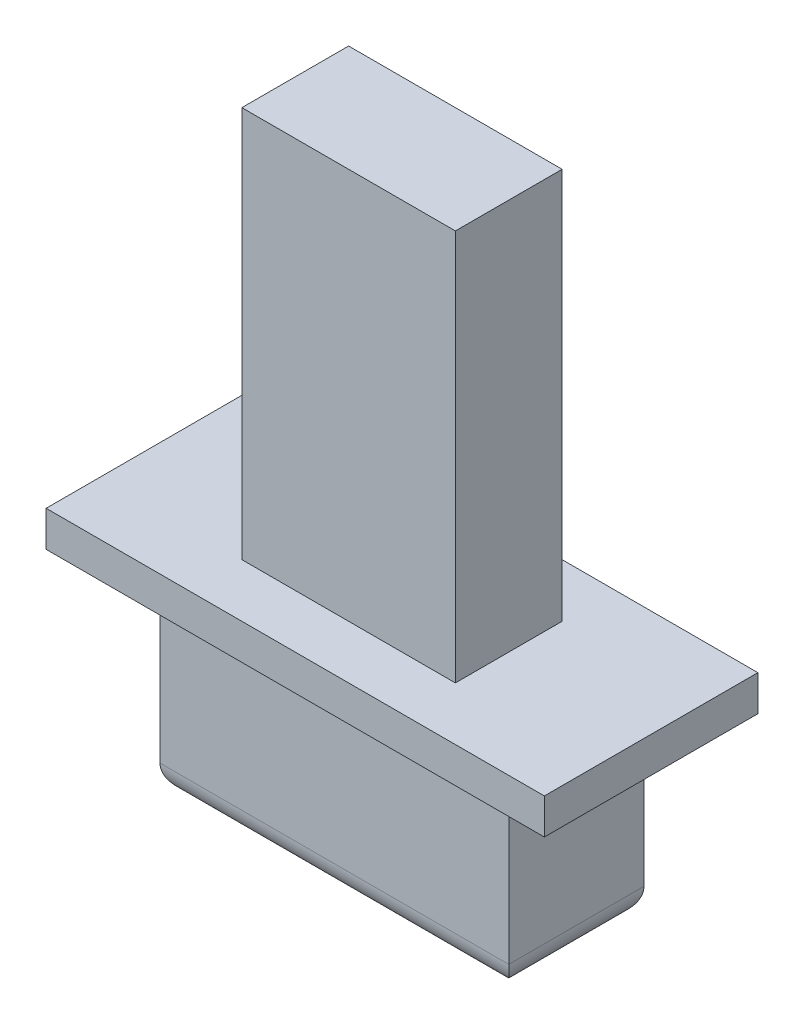
from build123d import *

# Parameters (mm, degrees)
SKETCH1_W           = 4.9
SKETCH1_H           = 1.9
BOSS_EXTRUDE1_DEPTH = 2.75
SKETCH2_W           = 3
SKETCH2_H           = 1.5
BOSS_EXTRUDE2_DEPTH = 6
FILLET2_R           = 0.4
SKETCH3_W           = 7
SKETCH3_H           = 3
BOSS_EXTRUDE3_DEPTH = 0.5


with BuildPart() as part:
    # Sketch1 → Boss-Extrude1 (new body)
    with BuildSketch(Plane(origin=(0, 0, 0), x_dir=(1, 0, 0), z_dir=(0, 1, 0))):
        Rectangle(SKETCH1_W, SKETCH1_H)
    extrude(amount=BOSS_EXTRUDE1_DEPTH)

    # Sketch2 → Boss-Extrude2 (add)
    with BuildSketch(Plane(origin=(0, 2.75, 0), x_dir=(1, 0, 0), z_dir=(0, 1, 0))):
        Rectangle(SKETCH2_W, SKETCH2_H)
    extrude(amount=BOSS_EXTRUDE2_DEPTH)

    # Fillet2
    fillet2_edges = [part.edges().sort_by_distance(p)[0] for p in [
        (0, 0, -0.95),
        (2.45, 0, 0),
        (0, 0, 0.95),
        (-2.45, 0, 0),
    ]]
    fillet(fillet2_edges, radius=FILLET2_R)


with BuildPart() as body_2:
    # Sketch3 → Boss-Extrude3 (new body)
    with BuildSketch(Plane(origin=(0, 2.75, 0), x_dir=(1, 0, 0), z_dir=(0, 1, 0))):
        Rectangle(SKETCH3_W, SKETCH3_H)
    extrude(amount=BOSS_EXTRUDE3_DEPTH)


solid = Compound([part.part, body_2.part])
